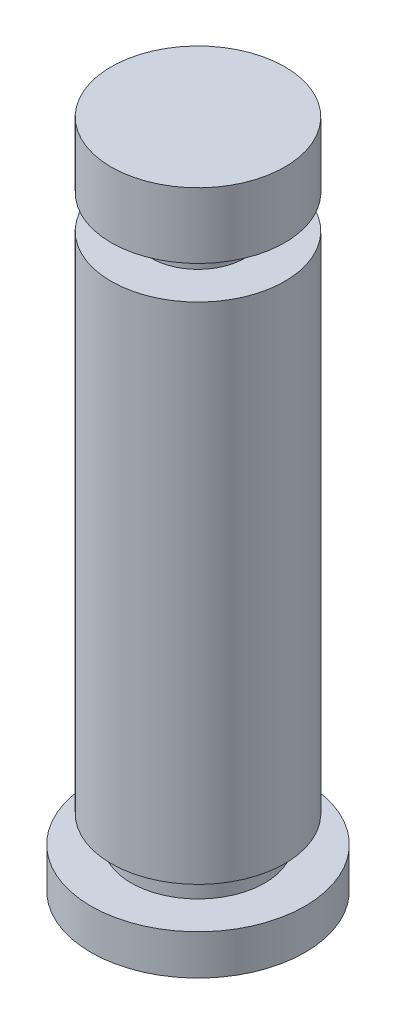
from build123d import *


with BuildPart() as part:
    # Sketch1 → Revolve1 (revolve)
    with BuildSketch(Plane.XY, mode=Mode.PRIVATE) as revolve1_sk:
        Polygon((0, 0), (-8, 0), (-8, 3), (-5, 3), (-5, 5), (-6.4925, 5), (-6.4925, 42.7), (-3.5, 42.7), (-3.5, 45.2), (-6.4925, 45.2), (-6.4925, 50.1), (0, 50.1), align=None)
    revolve(revolve1_sk.sketch.rotate(Axis((0, 0, 0), (0, 1, 0)), 270), axis=Axis((0, 0, 0), (0, 1, 0)))  # turned: the seam where the file's is


solid = part.part
